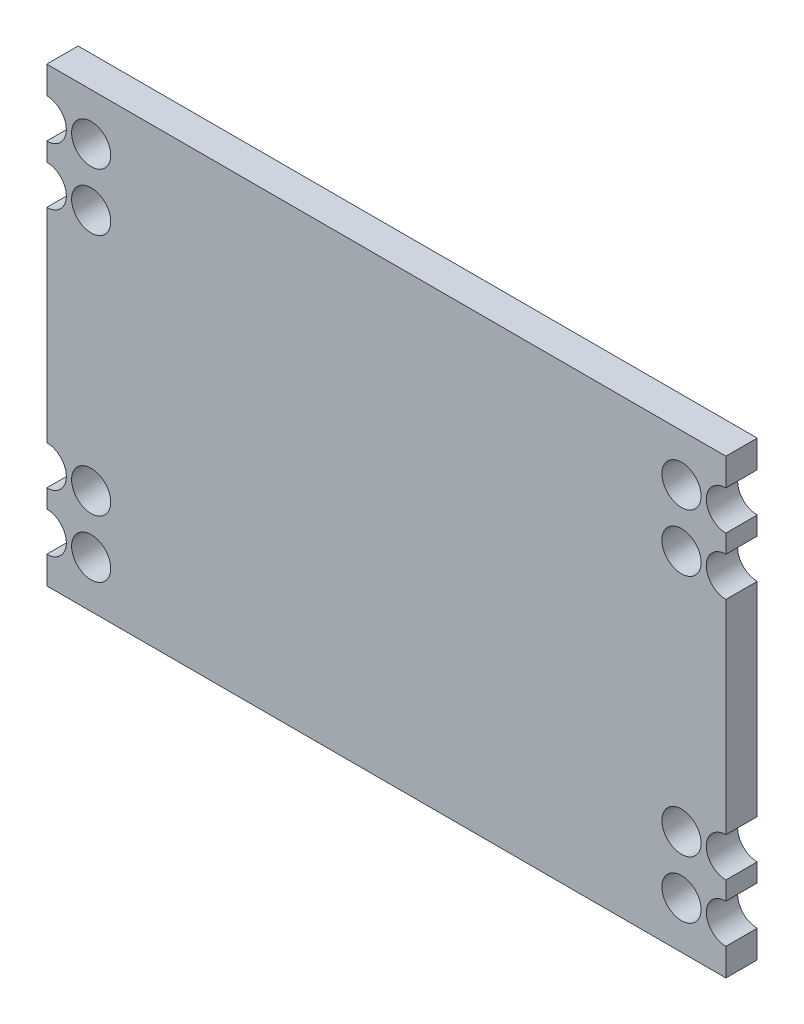
from build123d import *

# Parameters (mm, degrees)
SKETCH1_R           = 0.75
BOSS_EXTRUDE1_DEPTH = 1.2


with BuildPart() as part:
    # Sketch1 → Boss-Extrude1 (new body)
    with BuildSketch(Plane.XY):
        with BuildLine():
            Line((13, 8.65), (-13, 8.65))
            Line((-13, 8.65), (-13, 7.6))
            ThreePointArc((-13, 7.6), (-12.469669914, 7.380330086), (-12.25, 6.85))
            ThreePointArc((-12.25, 6.85), (-12.469669914, 6.319669914), (-13, 6.1))
            Line((-13, 6.1), (-13, 5.4))
            ThreePointArc((-13, 5.4), (-12.469669914, 5.180330086), (-12.25, 4.65))
            ThreePointArc((-12.25, 4.65), (-12.469669914, 4.119669914), (-13, 3.9))
            Line((-13, 3.9), (-13, -3.9))
            ThreePointArc((-13, -3.9), (-12.469669914, -4.119669914), (-12.25, -4.65))
            ThreePointArc((-12.25, -4.65), (-12.469669914, -5.180330086), (-13, -5.4))
            Line((-13, -5.4), (-13, -6.1))
            ThreePointArc((-13, -6.1), (-12.469669914, -6.319669914), (-12.25, -6.85))
            ThreePointArc((-12.25, -6.85), (-12.469669914, -7.380330086), (-13, -7.6))
            Line((-13, -7.6), (-13, -8.65))
            Line((-13, -8.65), (13, -8.65))
            Line((13, -8.65), (13, -7.6))
            ThreePointArc((13, -7.6), (12.25, -6.85), (13, -6.1))
            Line((13, -6.1), (13, -5.4))
            ThreePointArc((13, -5.4), (12.25, -4.65), (13, -3.9))
            Line((13, -3.9), (13, 3.9))
            ThreePointArc((13, 3.9), (12.25, 4.65), (13, 5.4))
            Line((13, 5.4), (13, 6.1))
            ThreePointArc((13, 6.1), (12.25, 6.85), (13, 7.6))
            Line((13, 7.6), (13, 8.65))
        make_face()
        with Locations((-11.3, -6.85)):
            Circle(SKETCH1_R, mode=Mode.SUBTRACT)
        with Locations((-11.3, -4.65)):
            Circle(SKETCH1_R, mode=Mode.SUBTRACT)
        with Locations((11.3, -6.85)):
            Circle(SKETCH1_R, mode=Mode.SUBTRACT)
        with Locations((11.3, -4.65)):
            Circle(SKETCH1_R, mode=Mode.SUBTRACT)
        with Locations((-11.3, 4.65)):
            Circle(SKETCH1_R, mode=Mode.SUBTRACT)
        with Locations((-11.3, 6.85)):
            Circle(SKETCH1_R, mode=Mode.SUBTRACT)
        with Locations((11.3, 4.65)):
            Circle(SKETCH1_R, mode=Mode.SUBTRACT)
        with Locations((11.3, 6.85)):
            Circle(SKETCH1_R, mode=Mode.SUBTRACT)
    extrude(amount=BOSS_EXTRUDE1_DEPTH)


solid = part.part
